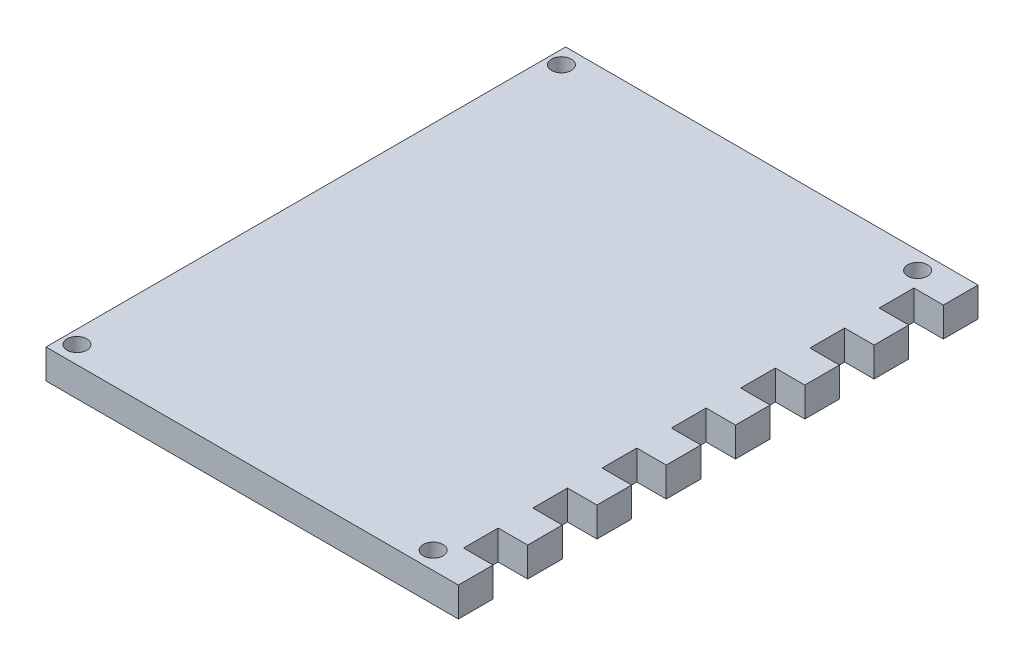
from build123d import *

# Parameters (mm, degrees)
SKETCH1_R           = 1.6
BOSS_EXTRUDE1_DEPTH = 4.7625


with BuildPart() as part:
    # Sketch1 → Boss-Extrude1 (new body)
    with BuildSketch(Plane(origin=(0, 0, 0), x_dir=(1, 0, 0), z_dir=(0, 1, 0))):
        Polygon((0, 0), (61.9, 0), (66.6625, 0), (66.6625, 5.6), (61.9, 5.6), (61.9, 11.2), (66.6625, 11.2), (66.6625, 16.8), (61.9, 16.8), (61.9, 22.4), (66.6625, 22.4), (66.6625, 28), (61.9, 28), (61.9, 33.6), (66.6625, 33.6), (66.6625, 39.2), (61.9, 39.2), (61.9, 44.8), (66.6625, 44.8), (66.6625, 50.4), (61.9, 50.4), (61.9, 56), (66.6625, 56), (66.6625, 61.6), (61.9, 61.6), (61.9, 67.2), (66.6625, 67.2), (66.6625, 72.8), (61.9, 72.8), (61.9, 78.4), (66.6625, 78.4), (66.6625, 84), (61.9, 84), (0, 84), align=None)
        with Locations((2.16, 81.16)):
            Circle(SKETCH1_R, mode=Mode.SUBTRACT)
        with Locations((2.16, 2.84)):
            Circle(SKETCH1_R, mode=Mode.SUBTRACT)
        with Locations((59.74, 2.84)):
            Circle(SKETCH1_R, mode=Mode.SUBTRACT)
        with Locations((59.74, 81.16)):
            Circle(SKETCH1_R, mode=Mode.SUBTRACT)
    extrude(amount=BOSS_EXTRUDE1_DEPTH)


solid = part.part
